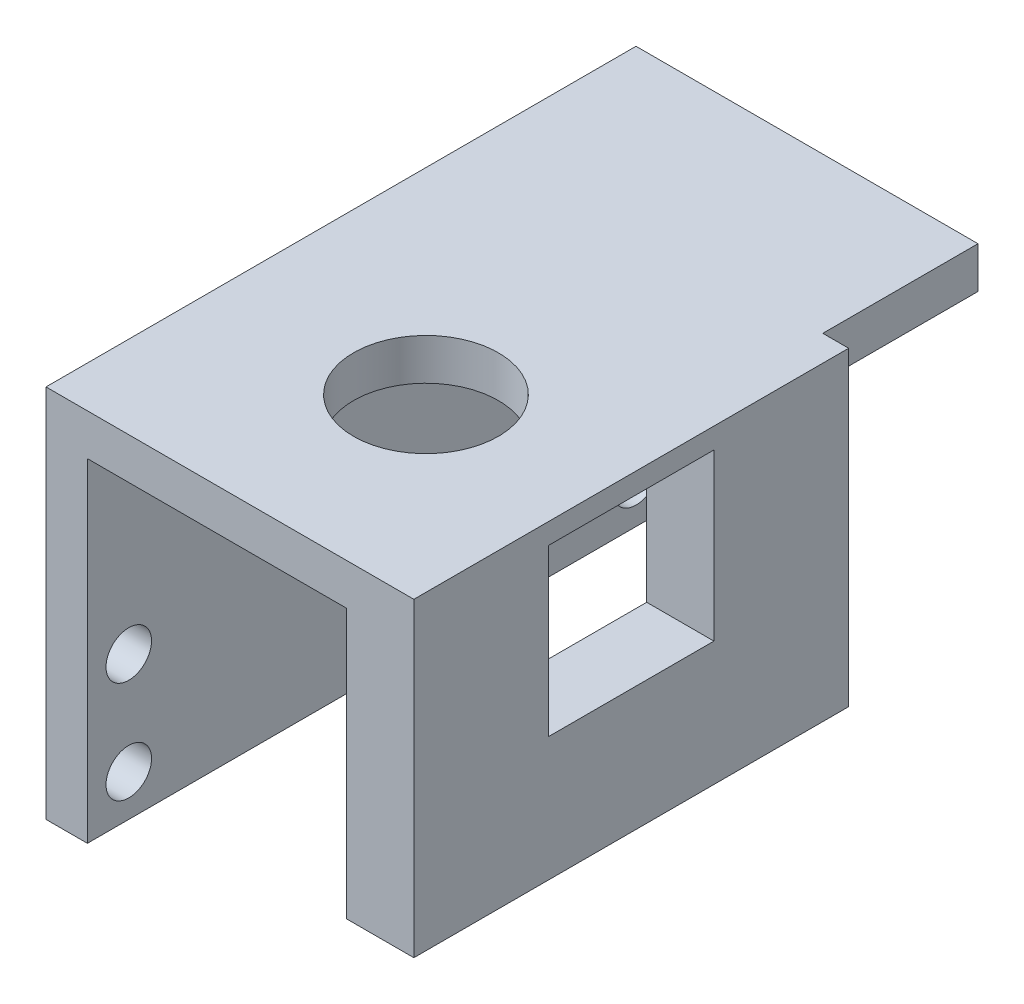
from build123d import *

# Parameters (mm, degrees)
SKETCH1_W           = 57.02
SKETCH1_H           = 36.2
SKETCH1_R           = 2.2
BOSS_EXTRUDE1_DEPTH = 4
SKETCH2_W           = 57.02
SKETCH2_H           = 4
BOSS_EXTRUDE2_DEPTH = 29.05
SKETCH3_W           = 4
SKETCH3_H           = 42.02
BOSS_EXTRUDE3_DEPTH = 26
SKETCH5_R           = 7
CUT_EXTRUDE1_DEPTH  = 4
SKETCH6_W           = 42.02
SKETCH6_H           = 30
BOSS_EXTRUDE4_DEPTH = 2.5
SKETCH7_W           = 16
SKETCH7_H           = 16
CUT_EXTRUDE2_DEPTH  = 6.5


with BuildPart() as part:
    # Sketch1 → Boss-Extrude1 (new body)
    with BuildSketch(Plane(origin=(0, 0, 0), x_dir=(0, 0, -1), z_dir=(1, 0, 0))):
        Rectangle(SKETCH1_W, SKETCH1_H)
        with Locations((-24.51, -4.25)):
            Circle(SKETCH1_R, mode=Mode.SUBTRACT)
        with Locations((-24.51, -14.1)):
            Circle(SKETCH1_R, mode=Mode.SUBTRACT)
        with Locations((24.51, -4.25)):
            Circle(SKETCH1_R, mode=Mode.SUBTRACT)
        with Locations((24.51, -14.1)):
            Circle(SKETCH1_R, mode=Mode.SUBTRACT)
    extrude(amount=BOSS_EXTRUDE1_DEPTH)

    # Sketch2 → Boss-Extrude2 (add)
    with BuildSketch(Plane(origin=(4, 0, 0), x_dir=(0, 0, -1), z_dir=(1, 0, 0))):
        with Locations((0, 16.1)):
            Rectangle(SKETCH2_W, SKETCH2_H)
    extrude(amount=BOSS_EXTRUDE2_DEPTH)

    # Sketch3 → Boss-Extrude3 (add)
    with BuildSketch(Plane.XZ.offset(-14.1)):
        with Locations((31.05, 7.5)):
            Rectangle(SKETCH3_W, SKETCH3_H)
    extrude(amount=BOSS_EXTRUDE3_DEPTH)

    # Sketch5 → Cut-Extrude1 (cut)
    with BuildSketch(Plane(origin=(0, 18.1, 0), x_dir=(1, 0, 0), z_dir=(0, 1, 0))):
        with Locations((19, -10.79)):
            Circle(SKETCH5_R)
    extrude(amount=-CUT_EXTRUDE1_DEPTH, mode=Mode.SUBTRACT)

    # Sketch6 → Boss-Extrude4 (add)
    with BuildSketch(Plane(origin=(33.05, 0, 0), x_dir=(0, 0, -1), z_dir=(1, 0, 0))):
        with Locations((-7.5, 3.1)):
            Rectangle(SKETCH6_W, SKETCH6_H)
    extrude(amount=BOSS_EXTRUDE4_DEPTH)

    # Sketch7 → Cut-Extrude2 (cut)
    with BuildSketch(Plane(origin=(35.55, 0, 0), x_dir=(0, 0, -1), z_dir=(1, 0, 0))):
        with Locations((-7.51, 8.1)):
            Rectangle(SKETCH7_W, SKETCH7_H)
    extrude(amount=-CUT_EXTRUDE2_DEPTH, mode=Mode.SUBTRACT)


solid = part.part
